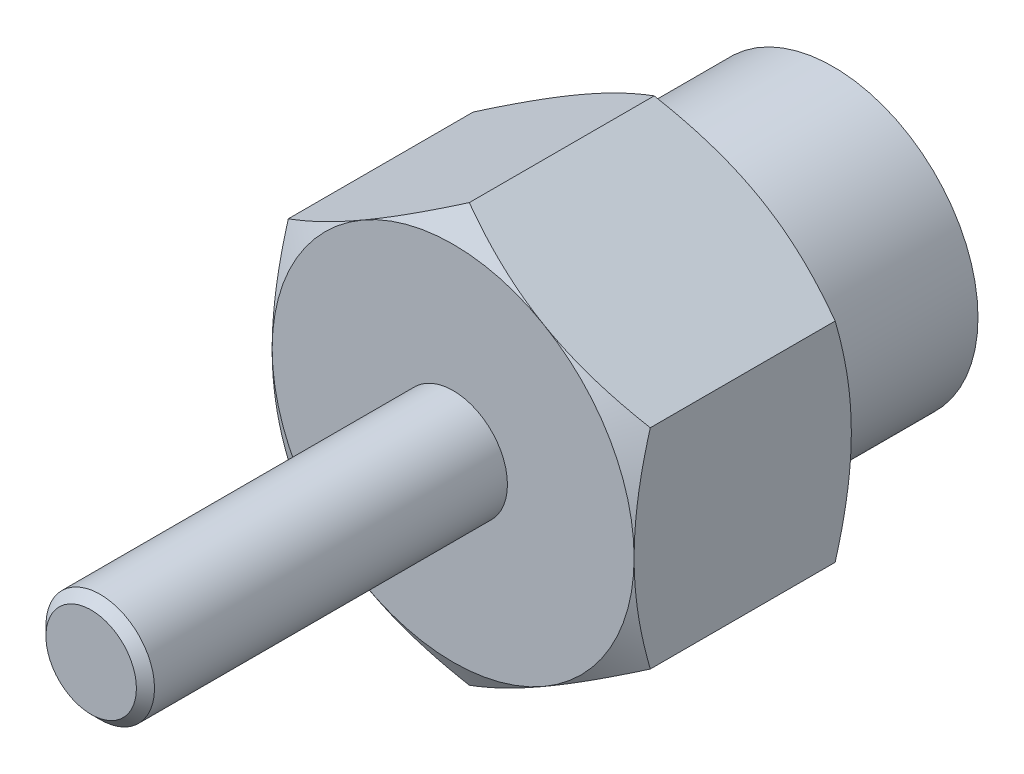
from build123d import *

# Parameters (mm, degrees)
BOSS_EXTRU_1_DEPTH      = 3
ESQUISSE2_OUTSIDE_W     = 36.066
ESQUISSE2_OUTSIDE_H     = 37.614
ESQUISSE2_OUTSIDE_R     = 5
ENL_V_MAT_EXTRU_1_DEPTH = 6
ENL_V_MAT_EXTRU_1_TAPER = 60
ESQUISSE3_R             = 4
BOSS_EXTRU_2_DEPTH      = 4.5
ESQUISSE4_R             = 1.5
BOSS_EXTRU_3_DEPTH      = 10
CHANFREIN1_SIZE         = 0.25


with BuildPart() as part:
    # Esquisse1 → Boss.-Extru.1 (new body, symmetric)
    with BuildSketch(Plane.XY):
        Polygon((0, -5.773502692), (5, -2.886751346), (5, 2.886751346), (0, 5.773502692), (-5, 2.886751346), (-5, -2.886751346), align=None)
    extrude(amount=BOSS_EXTRU_1_DEPTH, both=True)

    # Esquisse2 outside → Enlèv. mat.-Extru.1 (cut)
    with BuildSketch(Plane.XY.offset(3)):
        Rectangle(ESQUISSE2_OUTSIDE_W, ESQUISSE2_OUTSIDE_H)
        Circle(ESQUISSE2_OUTSIDE_R, mode=Mode.SUBTRACT)
    enl_v_mat_extru_1 = extrude(amount=-ENL_V_MAT_EXTRU_1_DEPTH, taper=ENL_V_MAT_EXTRU_1_TAPER, mode=Mode.SUBTRACT)

    # Esquisse3 → Boss.-Extru.2 (add)
    with BuildSketch(Plane(origin=(0, 0, -3), x_dir=(-1, 0, 0), z_dir=(0, 0, -1))):
        Circle(ESQUISSE3_R)
    extrude(amount=BOSS_EXTRU_2_DEPTH)

    # Esquisse4 → Boss.-Extru.3 (add)
    with BuildSketch(Plane.XY.offset(3)):
        Circle(ESQUISSE4_R)
    extrude(amount=BOSS_EXTRU_3_DEPTH)

    # Chanfrein1
    chanfrein1_edges = [part.edges().sort_by_distance(p)[0] for p in [
        (-1.5, 0, 13),
    ]]
    chamfer(chanfrein1_edges, length=CHANFREIN1_SIZE)

    # Symétrie1: Enlèv. mat.-Extru.1 across plane
    add(enl_v_mat_extru_1.mirror(Plane.XY), mode=Mode.SUBTRACT)


solid = part.part
